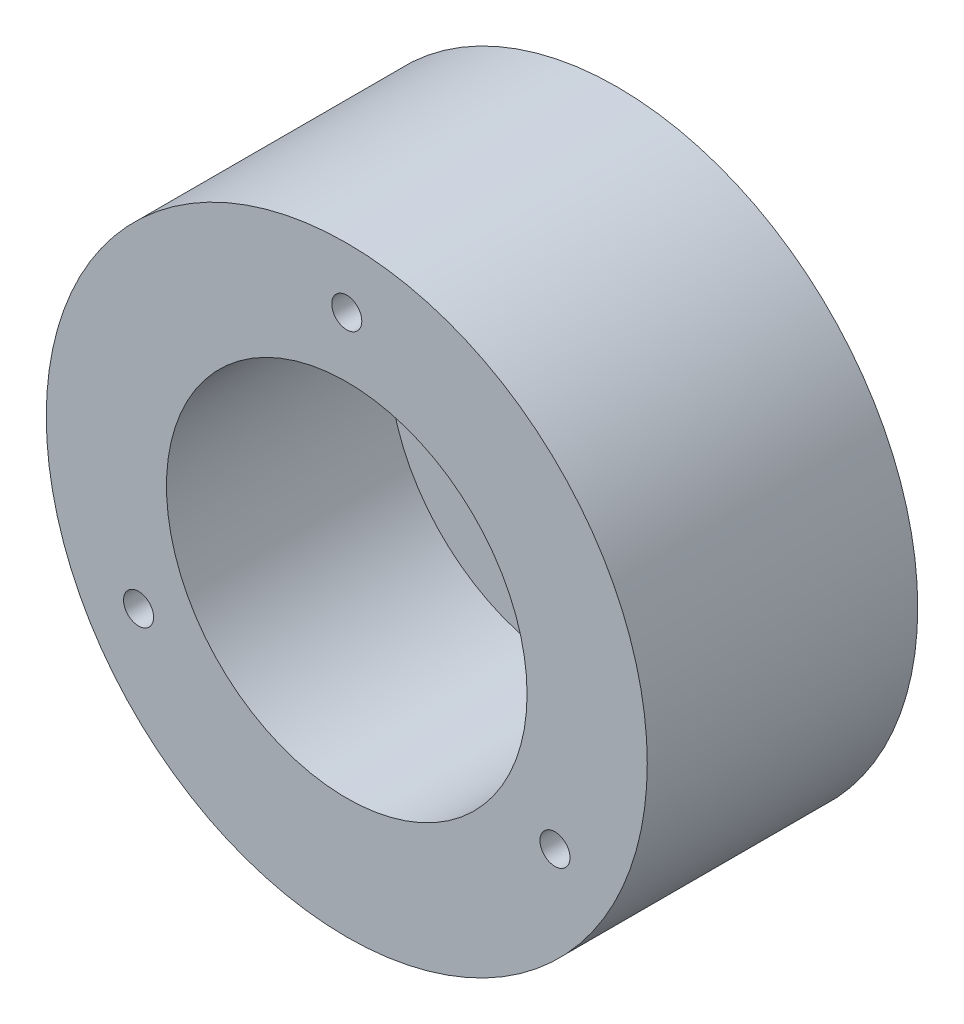
from build123d import *

# Parameters (mm, degrees)
SKETCH1_R           = 50
SKETCH1_R_2         = 16
BOSS_EXTRUDE1_DEPTH = 8
SKETCH2_R           = 50
SKETCH2_R_2         = 30
BOSS_EXTRUDE2_DEPTH = 37
SKETCH3_R           = 2.5
CUT_EXTRUDE1_DEPTH  = 46
SKETCH4_R           = 2.5
CUT_EXTRUDE2_DEPTH  = 9


with BuildPart() as part:
    # Sketch1 → Boss-Extrude1 (new body)
    with BuildSketch(Plane.XY):
        Circle(SKETCH1_R)
        Circle(SKETCH1_R_2, mode=Mode.SUBTRACT)
    extrude(amount=BOSS_EXTRUDE1_DEPTH)

    # Sketch2 → Boss-Extrude2 (add)
    with BuildSketch(Plane.XY.offset(8)):
        Circle(SKETCH2_R)
        Circle(SKETCH2_R_2, mode=Mode.SUBTRACT)
    extrude(amount=BOSS_EXTRUDE2_DEPTH)

    # Sketch3 → Cut-Extrude1 (cut, through all)
    with BuildSketch(Plane.XY.offset(45)):
        with Locations((0, 40)):
            Circle(SKETCH3_R)
        with Locations((34.641016151, -20)):
            Circle(SKETCH3_R)
        with Locations((-34.641016151, -20)):
            Circle(SKETCH3_R)
    extrude(amount=-CUT_EXTRUDE1_DEPTH, mode=Mode.SUBTRACT)

    # Sketch4 → Cut-Extrude2 (cut, through all)
    with BuildSketch(Plane.XY.offset(8)):
        with Locations((0, 20)):
            Circle(SKETCH4_R)
        with Locations((20, 0)):
            Circle(SKETCH4_R)
        with Locations((0, -20)):
            Circle(SKETCH4_R)
        with Locations((-20, 0)):
            Circle(SKETCH4_R)
    extrude(amount=-CUT_EXTRUDE2_DEPTH, mode=Mode.SUBTRACT)


solid = part.part
